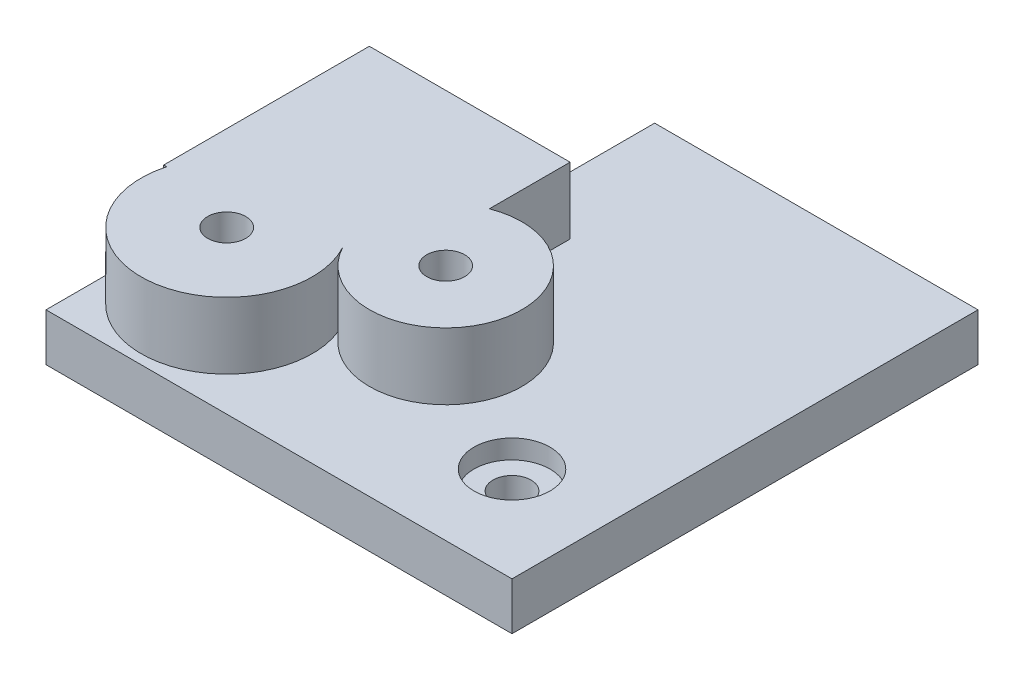
from build123d import *

# Parameters (mm, degrees)
SKETCH1_R           = 2
BOSS_EXTRUDE1_DEPTH = 5
SKETCH2_R           = 4
CUT_EXTRUDE1_DEPTH  = 2
SKETCH3_R           = 2
BOSS_EXTRUDE2_DEPTH = 12
SKETCH4_W           = 51.589864231
SKETCH4_H           = 45.63525298
CUT_EXTRUDE2_DEPTH  = 5


with BuildPart() as part:
    # Sketch1 → Boss-Extrude1 (new body)
    with BuildSketch(Plane(origin=(0, 0, 0), x_dir=(1, 0, 0), z_dir=(0, 1, 0))):
        Polygon((0, 34), (0, 0), (49, 0), (49, 49), (15, 49), (15, 34), align=None)
        with Locations((9, 10)):
            Circle(SKETCH1_R, mode=Mode.SUBTRACT)
        with Locations((24, 18.03)):
            Circle(SKETCH1_R, mode=Mode.SUBTRACT)
        with Locations((39, 10)):
            Circle(SKETCH1_R, mode=Mode.SUBTRACT)
    extrude(amount=BOSS_EXTRUDE1_DEPTH)

    # Sketch2 → Cut-Extrude1 (cut)
    with BuildSketch(Plane(origin=(0, 5, 0), x_dir=(1, 0, 0), z_dir=(0, 1, 0))):
        with Locations((39, 10)):
            Circle(SKETCH2_R)
    extrude(amount=-CUT_EXTRUDE1_DEPTH, mode=Mode.SUBTRACT)

    # Sketch3 → Boss-Extrude2 (add)
    with BuildSketch(Plane(origin=(0, 5, 0), x_dir=(1, 0, 0), z_dir=(0, 1, 0))):
        with BuildLine():
            Line((15, 34), (0, 34))
            Line((0, 34), (0, 12.373527554))
            Line((0, 12.373527554), (0.318619525, 12.373527554))
            ThreePointArc((0.318619525, 12.373527554), (7.991284246, 18.943293159), (16.934577194, 14.247644612))
            ThreePointArc((16.934577194, 14.247644612), (16.486188802, 20.817302098), (21.110631854, 25.505156415))
            Line((21.110631854, 25.505156415), (21.110631854, 34))
            Line((21.110631854, 34), (15, 34))
        make_face()
        with BuildLine():
            Line((21.110631854, 12.373527554), (21.110631854, 25.505156415))
            ThreePointArc((21.110631854, 25.505156415), (16.486188802, 20.817302098), (16.934577194, 14.247644612))
            ThreePointArc((16.934577194, 14.247644612), (17.560142752, 13.25981653), (18.322788434, 12.373527554))
            Line((18.322788434, 12.373527554), (21.110631854, 12.373527554))
        make_face()
        with BuildLine():
            ThreePointArc((16.934577194, 14.247644612), (7.991284246, 18.943293159), (0.318619525, 12.373527554))
            Line((0.318619525, 12.373527554), (17.681380475, 12.373527554))
            ThreePointArc((17.681380475, 12.373527554), (17.360657331, 13.331577554), (16.934577194, 14.247644612))
        make_face()
        with BuildLine():
            ThreePointArc((32.014138239, 18.03), (28.531590006, 24.639924638), (21.110631854, 25.505156415))
            Line((21.110631854, 25.505156415), (21.110631854, 12.373527554))
            Line((21.110631854, 12.373527554), (18.322788434, 12.373527554))
            ThreePointArc((18.322788434, 12.373527554), (27.060102401, 10.623098826), (32.014138239, 18.03))
        make_face()
        with Locations((24, 18.03)):
            Circle(SKETCH3_R, mode=Mode.SUBTRACT)
        with BuildLine():
            Line((17.681380475, 12.373527554), (0.318619525, 12.373527554))
            ThreePointArc((0.318619525, 12.373527554), (0.08001053, 11.197408812), (0, 10))
            ThreePointArc((0, 10), (9, 1), (18, 10))
            ThreePointArc((18, 10), (17.91998947, 11.197408812), (17.681380475, 12.373527554))
        make_face()
        with Locations((9, 10)):
            Circle(SKETCH3_R, mode=Mode.SUBTRACT)
    extrude(amount=BOSS_EXTRUDE2_DEPTH)

    # Sketch4 → Cut-Extrude2 (cut)
    with BuildSketch(Plane(origin=(0, 17, 0), x_dir=(1, 0, 0), z_dir=(0, 1, 0))):
        with Locations((25.794932115, 11.18237351)):
            Rectangle(SKETCH4_W, SKETCH4_H)
    extrude(amount=-CUT_EXTRUDE2_DEPTH, mode=Mode.SUBTRACT)


solid = part.part
